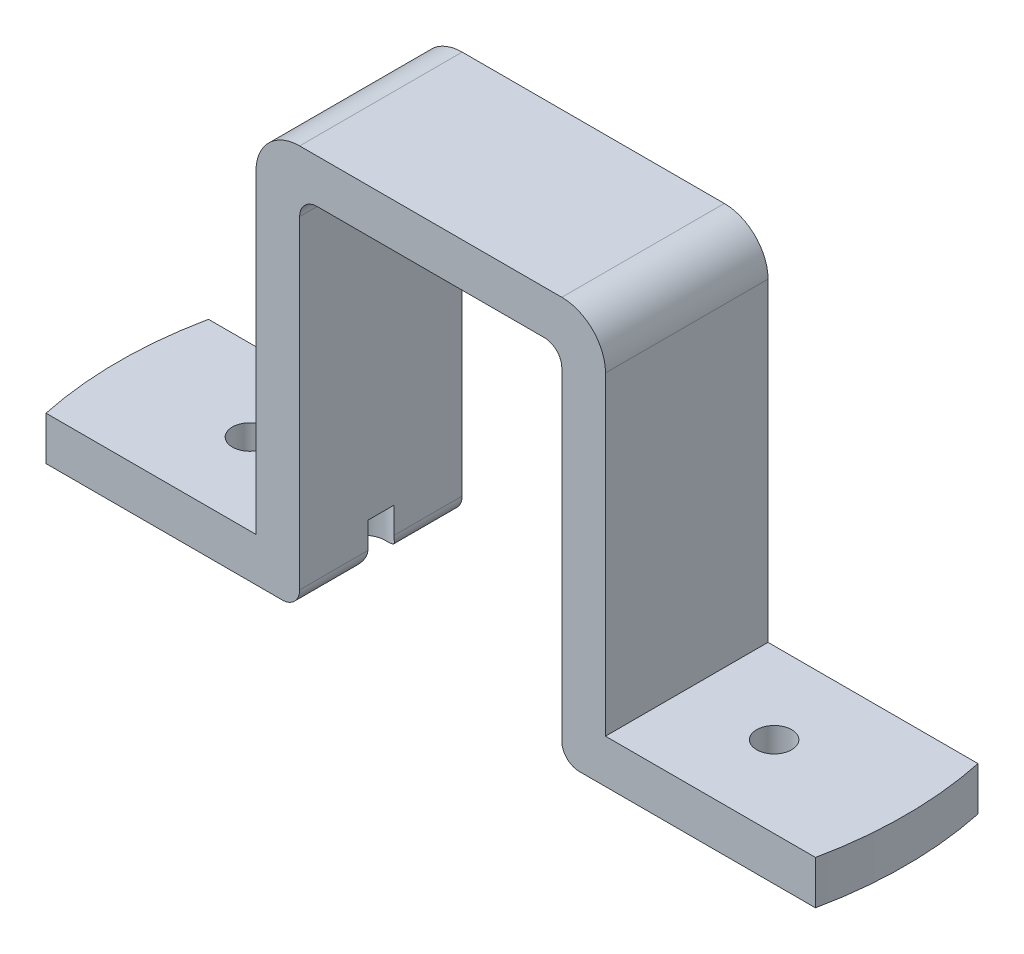
from build123d import *

# Parameters (mm, degrees)
BOSS_EXTRUDE1_DEPTH = 18.6
SKETCH2_R           = 2
SKETCH2_R_2         = 2.5
CUT_EXTRUDE1_DEPTH  = 10
SKETCH3_R           = 50
SKETCH3_R_2         = 45
CUT_EXTRUDE2_DEPTH  = 60
FILLET1_R           = 5
FILLET2_R           = 5
FILLET3_R           = 2
FILLET4_R           = 2


with BuildPart() as part:
    # Sketch1 → Boss-Extrude1 (new body)
    with BuildSketch(Plane.XY):
        Polygon((90, 5), (90, 0), (60, 0), (60, 41), (30, 41), (30, 0), (0, 0), (0, 5), (25, 5), (25, 46), (65, 46), (65, 5), align=None)
    extrude(amount=BOSS_EXTRUDE1_DEPTH)

    # Sketch2 → Cut-Extrude1 (cut)
    with BuildSketch(Plane(origin=(0, 5, 0), x_dir=(1, 0, 0), z_dir=(0, 1, 0))):
        with Locations((75, -9.3)):
            Circle(SKETCH2_R)
        with Locations((15, -9.3)):
            Circle(SKETCH2_R)
        with Locations((28, -9.3)):
            Circle(SKETCH2_R_2)
        with Locations((62, -9.3)):
            Circle(SKETCH2_R_2)
    extrude(amount=-CUT_EXTRUDE1_DEPTH, mode=Mode.SUBTRACT)

    # Sketch3 → Cut-Extrude2 (cut)
    with BuildSketch(Plane(origin=(0, 46, 0), x_dir=(1, 0, 0), z_dir=(0, 1, 0))):
        with Locations((45, -9.3)):
            Circle(SKETCH3_R)
        with Locations((45, -9.3)):
            Circle(SKETCH3_R_2, mode=Mode.SUBTRACT)
    extrude(amount=-CUT_EXTRUDE2_DEPTH, mode=Mode.SUBTRACT)

    # Fillet1
    fillet1_edges = [part.edges().sort_by_distance(p)[0] for p in [
        (25, 46, 9.3),
    ]]
    fillet(fillet1_edges, radius=FILLET1_R)

    # Fillet2
    fillet2_edges = [part.edges().sort_by_distance(p)[0] for p in [
        (65, 46, 9.3),
    ]]
    fillet(fillet2_edges, radius=FILLET2_R)

    # Fillet3
    fillet3_edges = [part.edges().sort_by_distance(p)[0] for p in [
        (60, 0, 14.7),
        (60, 41, 9.3),
        (30, 41, 9.3),
        (30, 0, 14.7),
    ]]
    fillet(fillet3_edges, radius=FILLET3_R)

    # Fillet4
    fillet4_edges = [part.edges().sort_by_distance(p)[0] for p in [
        (60, 0, 3.9),
        (30, 0, 3.9),
    ]]
    fillet(fillet4_edges, radius=FILLET4_R)


solid = part.part
